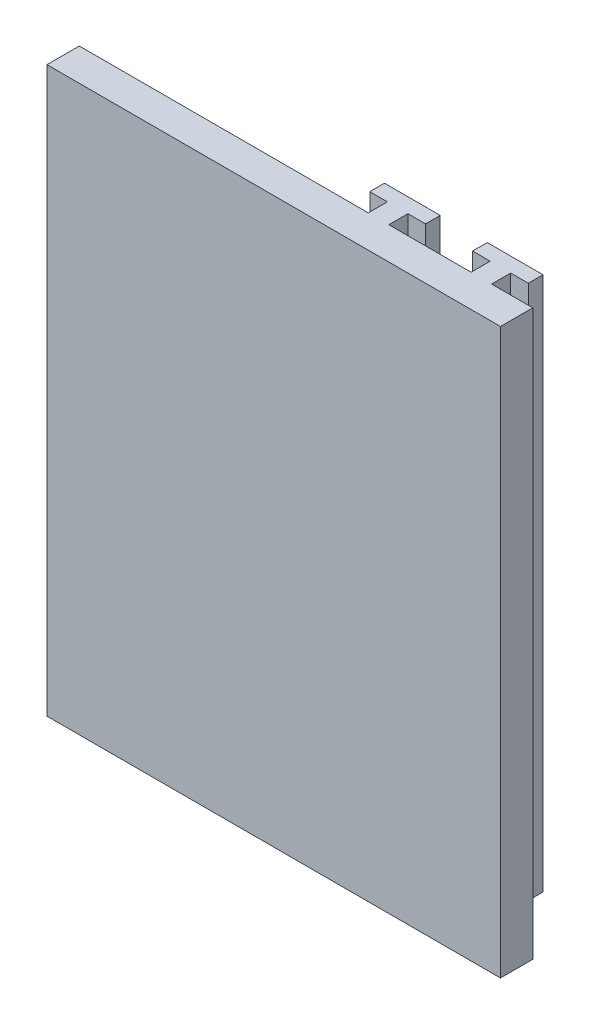
from build123d import *

# Parameters (mm, degrees)
SKETCH_1_W          = 120
SKETCH_1_H          = 140
EXTRUDE_1_DEPTH     = 5.5
EXTRUDE_13_DEPTH    = 91
SKETCH_26_W         = 120
SKETCH_26_H         = 43.949941981
CUT_EXTRUDE_1_DEPTH = 10
SKETCH_27_W         = 42.806130355
SKETCH_27_H         = 96.050058019
CUT_EXTRUDE_2_DEPTH = 12.25


with BuildPart() as part:
    # 草图1 → 凸台-拉伸1 (new body)
    with BuildSketch(Plane.XY.offset(133)):
        with Locations((-63.049709027, -28.203400415)):
            Rectangle(SKETCH_1_W, SKETCH_1_H)
    extrude(amount=EXTRUDE_1_DEPTH)

    # 草图25 → 凸台-拉伸13 (add)
    with BuildSketch(Plane(origin=(0, 41.796599585, 0), x_dir=(1, 0, 0), z_dir=(0, 1, 0))):
        Polygon((-10.052220086, -133), (-10.052220086, -129.75), (-7.052220086, -129.75), (-7.052220086, -127.25), (-16.547197967, -127.25), (-16.547197967, -129.75), (-13.547197967, -129.75), (-13.547197967, -133), align=None)
        Polygon((-27.552220086, -133), (-27.552220086, -129.75), (-24.552220086, -129.75), (-24.552220086, -127.25), (-34.047197967, -127.25), (-34.047197967, -129.75), (-31.047197967, -129.75), (-31.047197967, -133), align=None)
    extrude(amount=-EXTRUDE_13_DEPTH)

    # 草图26 → 切除-拉伸1 (cut)
    with BuildSketch(Plane.XY.offset(138.5)):
        with Locations((-63.049709027, -76.228429425)):
            Rectangle(SKETCH_26_W, SKETCH_26_H)
    extrude(amount=-CUT_EXTRUDE_1_DEPTH, mode=Mode.SUBTRACT)

    # 草图27 → 切除-拉伸2 (cut, through all)
    with BuildSketch(Plane.XY.offset(138.5)):
        with Locations((-101.64664385, -6.228429424)):
            Rectangle(SKETCH_27_W, SKETCH_27_H)
    extrude(amount=-CUT_EXTRUDE_2_DEPTH, mode=Mode.SUBTRACT)


solid = part.part
